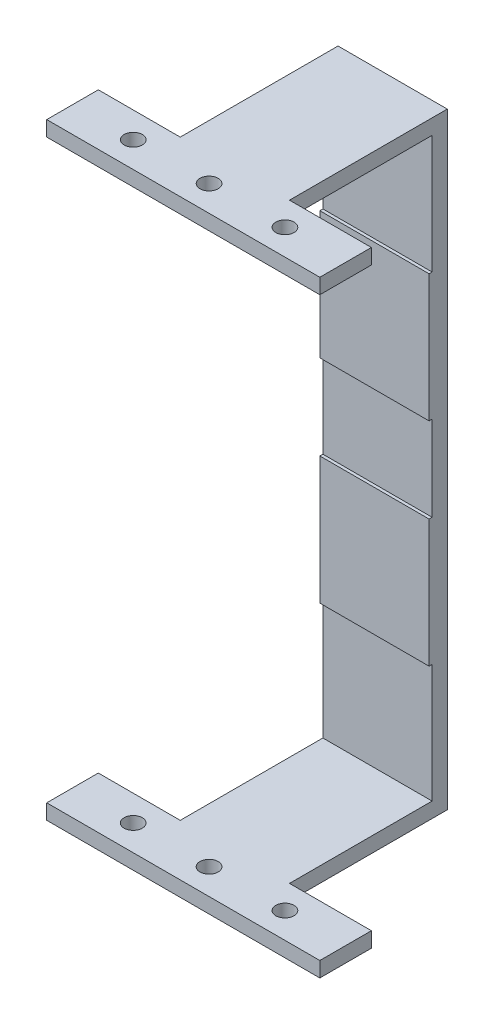
from build123d import *

# Parameters (mm, degrees)
CROQUIS1_W              = 90
CROQUIS1_H              = 200
SALIENTE_EXTRUIR1_DEPTH = 5
CROQUIS2_W              = 90
CROQUIS2_H              = 5
SALIENTE_EXTRUIR2_DEPTH = 64
CROQUIS3_W              = 36
CROQUIS3_H              = 42
SALIENTE_EXTRUIR3_DEPTH = 1
CROQUIS4_R              = 3
CORTAR_EXTRUIR1_DEPTH   = 201
CROQUIS5_W              = 27
CROQUIS5_H              = 190
CORTAR_EXTRUIR3_DEPTH   = 6
CROQUIS6_W              = 27
CROQUIS6_H              = 52
CORTAR_EXTRUIR4_DEPTH   = 201


with BuildPart() as part:
    # Croquis1 → Saliente-Extruir1 (new body)
    with BuildSketch(Plane.XY):
        Rectangle(CROQUIS1_W, CROQUIS1_H)
    extrude(amount=-SALIENTE_EXTRUIR1_DEPTH)

    # Croquis2 → Saliente-Extruir2 (add)
    with BuildSketch(Plane.XY):
        with Locations((0, 97.5)):
            Rectangle(CROQUIS2_W, CROQUIS2_H)
        with Locations((0, -97.5)):
            Rectangle(CROQUIS2_W, CROQUIS2_H)
    extrude(amount=SALIENTE_EXTRUIR2_DEPTH)

    # Croquis3 → Saliente-Extruir3 (add)
    with BuildSketch(Plane.XY):
        with Locations((0, 35)):
            Rectangle(CROQUIS3_W, CROQUIS3_H)
        with Locations((0, -35)):
            Rectangle(CROQUIS3_W, CROQUIS3_H)
    extrude(amount=SALIENTE_EXTRUIR3_DEPTH)

    # Croquis4 → Cortar-Extruir1 (cut, through all)
    with BuildSketch(Plane(origin=(0, 100, 0), x_dir=(1, 0, 0), z_dir=(0, 1, 0))):
        with Locations((-25, -55.5)):
            Circle(CROQUIS4_R)
        with Locations((0, -55.5)):
            Circle(CROQUIS4_R)
        with Locations((25, -55.5)):
            Circle(CROQUIS4_R)
    extrude(amount=-CORTAR_EXTRUIR1_DEPTH, mode=Mode.SUBTRACT)

    # Croquis5 → Cortar-Extruir3 (cut, through all)
    with BuildSketch(Plane.XY):
        with Locations((-31.5, 0)):
            Rectangle(CROQUIS5_W, CROQUIS5_H)
        with Locations((31.5, 0)):
            Rectangle(CROQUIS5_W, CROQUIS5_H)
    extrude(amount=-CORTAR_EXTRUIR3_DEPTH, mode=Mode.SUBTRACT)

    # Croquis6 → Cortar-Extruir4 (cut, through all)
    with BuildSketch(Plane(origin=(0, 100, 0), x_dir=(1, 0, 0), z_dir=(0, 1, 0))):
        with Locations((-31.5, -21)):
            Rectangle(CROQUIS6_W, CROQUIS6_H)
        with Locations((31.5, -21)):
            Rectangle(CROQUIS6_W, CROQUIS6_H)
    extrude(amount=-CORTAR_EXTRUIR4_DEPTH, mode=Mode.SUBTRACT)


solid = part.part
